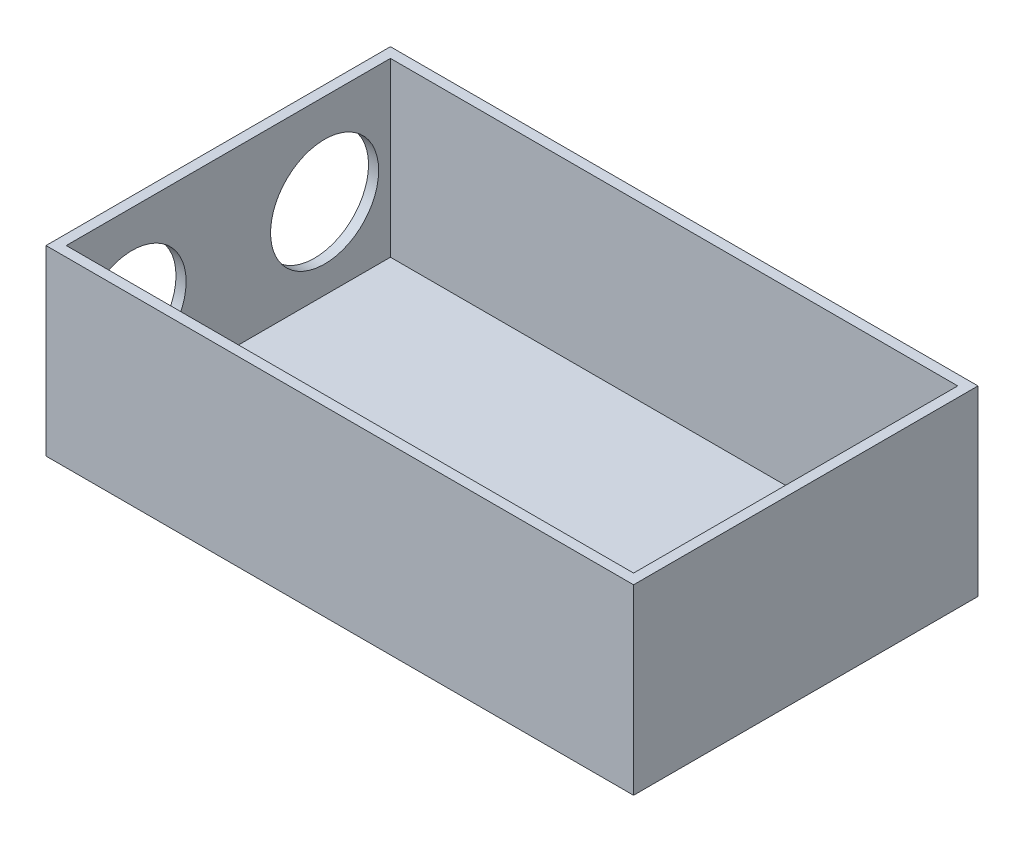
from build123d import *

# Parameters (mm, degrees)
SKETCH4_W           = 290
SKETCH4_H           = 170
BOSS_EXTRUDE1_DEPTH = 45
SHELL1_T            = -5
SKETCH5_R           = 26.67
CUT_EXTRUDE1_DEPTH  = 40


with BuildPart() as part:
    # Sketch4 → Boss-Extrude1 (new body, symmetric)
    with BuildSketch(Plane(origin=(0, 0, 0), x_dir=(1, 0, 0), z_dir=(0, 1, 0))):
        with Locations((35, 0)):
            Rectangle(SKETCH4_W, SKETCH4_H)
    extrude(amount=BOSS_EXTRUDE1_DEPTH, both=True)

    # Shell1
    shell1_openings = [part.faces().sort_by_distance(p)[0] for p in [
        (35, 45, 0),
    ]]
    offset(amount=SHELL1_T, openings=shell1_openings, kind=Kind.INTERSECTION)

    # Sketch5 → Cut-Extrude1 (cut, symmetric)
    with BuildSketch(Plane.ZY.offset(110)):
        with Locations((-47.514984282, 0)):
            Circle(SKETCH5_R)
        with Locations((47.514984282, 0)):
            Circle(SKETCH5_R)
    extrude(amount=CUT_EXTRUDE1_DEPTH, both=True, mode=Mode.SUBTRACT)


solid = part.part
